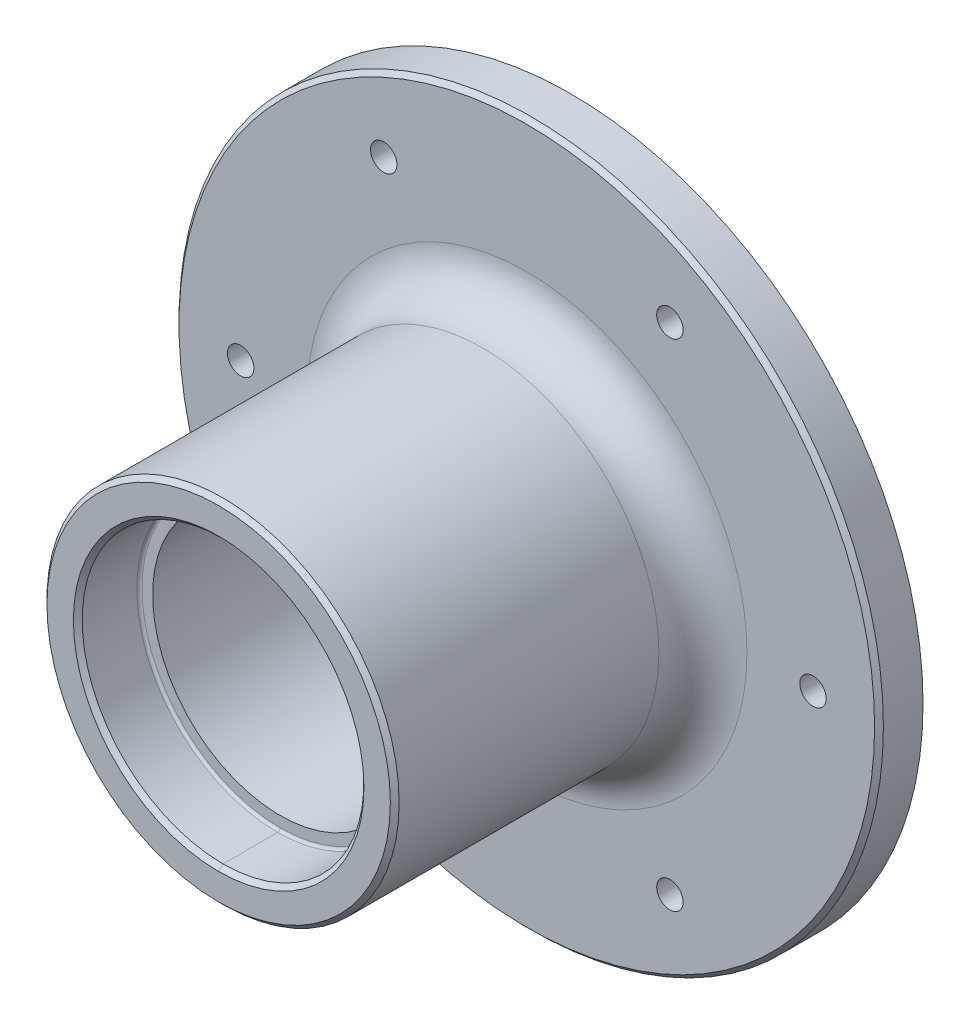
from build123d import *

# Parameters (mm, degrees)
SKETCH1_R           = 40
BOSS_EXTRUDE1_DEPTH = 5
SKETCH2_R           = 20
BOSS_EXTRUDE2_DEPTH = 35
M4_TAPPED_HOLE1_D   = 3
CIRPATTERN2_COUNT   = 6
CHAMFER2_SIZE       = 0.5
FILLET1_R           = 5
FILLET2_R           = 0.3


with BuildPart() as part:
    # Sketch1 → Boss-Extrude1 (new body)
    with BuildSketch(Plane.XY):
        Circle(SKETCH1_R)
    extrude(amount=BOSS_EXTRUDE1_DEPTH)

    # Sketch2 → Boss-Extrude2 (add)
    with BuildSketch(Plane.XY.offset(5)):
        Circle(SKETCH2_R)
    extrude(amount=BOSS_EXTRUDE2_DEPTH)

    # Sketch6 → Cut-Revolve2 (revolve, cut)
    with BuildSketch(Plane(origin=(0, 0, 0), x_dir=(0, 0, -1), z_dir=(1, 0, 0))):
        Polygon((0, 0), (-40, 0), (-40, 16), (-33, 16), (-33, 14.5), (-7, 14.5), (-7, 16), (0, 16), align=None)
    revolve(axis=Axis((0, 0, 56.301231345), (0, 0, -1)), mode=Mode.SUBTRACT)

    # M4 Tapped Hole1 (through all)
    with Locations(Plane(origin=(0, 0, 0), x_dir=(1, 0, 0), z_dir=(0, 0, -1))):
        with Locations((32.5, 0)):
            m4_tapped_hole1 = Hole(M4_TAPPED_HOLE1_D / 2)

    # CirPattern2: M4 Tapped Hole1 ×6 about axis
    cirpattern2_axis = Axis((0, 0, 0), (0, 0, 1))
    for i in range(1, CIRPATTERN2_COUNT):
        add(m4_tapped_hole1.rotate(cirpattern2_axis, i * 360 / CIRPATTERN2_COUNT), mode=Mode.SUBTRACT)

    # Chamfer2
    chamfer2_edges = [part.edges().sort_by_distance(p)[0] for p in [
        (0, -16, 40),
        (0, -16, 0),
        (-40, 0, 5),
        (0, -16, 0),
        (0, -16, 40),
        (-20, 0, 40),
    ]]
    chamfer(chamfer2_edges, length=CHAMFER2_SIZE)

    # Fillet1
    fillet1_edges = [part.edges().sort_by_distance(p)[0] for p in [
        (-20, 0, 5),
    ]]
    fillet(fillet1_edges, radius=FILLET1_R)

    # Fillet2
    fillet2_edges = [part.edges().sort_by_distance(p)[0] for p in [
        (0, -16, 33),
        (0, -16, 7),
        (0, -16, 7),
        (0, -16, 33),
    ]]
    fillet(fillet2_edges, radius=FILLET2_R)


solid = part.part
